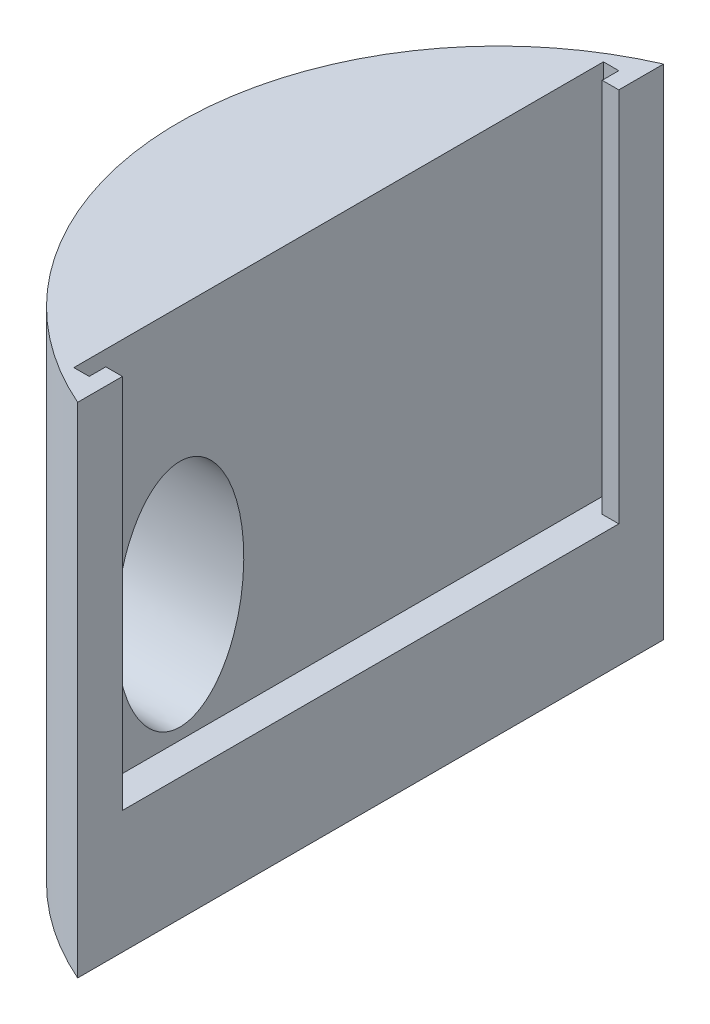
from build123d import *

# Parameters (mm, degrees)
BOSS_EXTRUDE1_DEPTH     = 39
CUT_EXTRUDE1_DEPTH      = 29.4
SKETCH3_RX              = 9
SKETCH3_RY              = 5
CUT_EXTRUDE2_DEPTH      = 3.5
CUT_EXTRUDE2_DEPTH_BACK = 13.5


with BuildPart() as part:
    # Sketch1 → Boss-Extrude1 (new body)
    with BuildSketch(Plane(origin=(0, 0, 0), x_dir=(1, 0, 0), z_dir=(0, 1, 0))):
        with BuildLine():
            Line((-10, 22.912878475), (-10, -22.912878475))
            ThreePointArc((-10, -22.912878475), (-25, 0), (-10, 22.912878475))
        make_face()
    extrude(amount=BOSS_EXTRUDE1_DEPTH)

    # Sketch2 → Cut-Extrude1 (cut)
    with BuildSketch(Plane(origin=(0, 39, 0), x_dir=(1, 0, 0), z_dir=(0, 1, 0))):
        Polygon((-10, 19.412878475), (-11.3, 19.412878475), (-11.3, 20.712878475), (-12.5, 20.712878475), (-12.5, -20.712878475), (-11.3, -20.712878475), (-11.3, -19.412878475), (-10, -19.412878475), align=None)
    extrude(amount=-CUT_EXTRUDE1_DEPTH, mode=Mode.SUBTRACT)

    # Sketch3 → Cut-Extrude2 (cut, two sides)
    with BuildSketch(Plane(origin=(-12.5, 0, 0), x_dir=(0, 0, -1), z_dir=(1, 0, 0))) as cut_extrude2_sk:
        with Locations(Location((-12.420207371, 19.5), (0, 0, 90))):
            Ellipse(SKETCH3_RX, SKETCH3_RY)
    extrude(amount=CUT_EXTRUDE2_DEPTH, mode=Mode.SUBTRACT)
    extrude(cut_extrude2_sk.sketch, amount=-CUT_EXTRUDE2_DEPTH_BACK, mode=Mode.SUBTRACT)


solid = part.part
